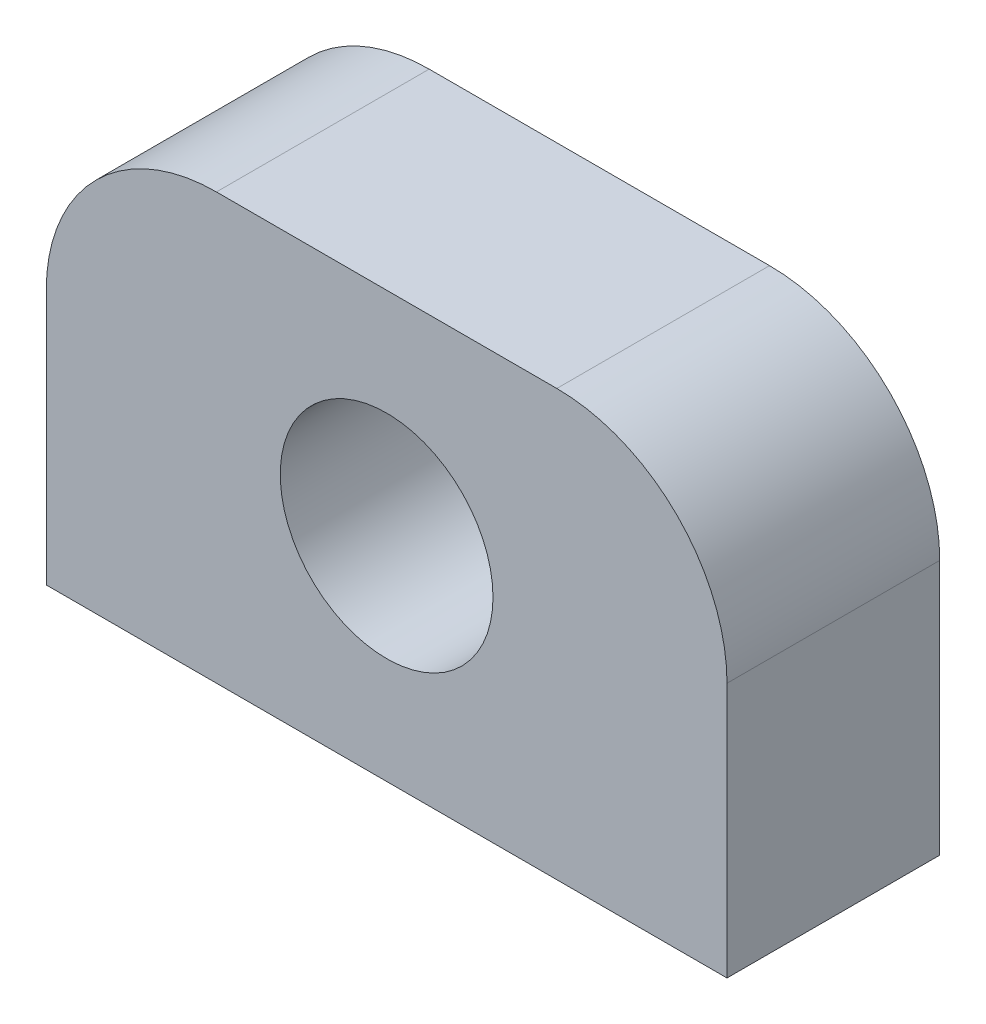
from build123d import *

# Parameters (mm, degrees)
SKETCH1_R           = 3.175
BOSS_EXTRUDE1_DEPTH = 6.35


with BuildPart() as part:
    # Sketch1 → Boss-Extrude1 (new body)
    with BuildSketch(Plane.XY):
        with BuildLine():
            Line((0, 0), (20.32, 0))
            Line((20.32, 0), (20.32, 7.62))
            ThreePointArc((20.32, 7.62), (18.832102448, 11.212102448), (15.24, 12.7))
            Line((15.24, 12.7), (5.08, 12.7))
            ThreePointArc((5.08, 12.7), (1.487897552, 11.212102448), (0, 7.62))
            Line((0, 7.62), (0, 0))
        make_face()
        with Locations((10.16, 6.35)):
            Circle(SKETCH1_R, mode=Mode.SUBTRACT)
    extrude(amount=BOSS_EXTRUDE1_DEPTH)


solid = part.part
